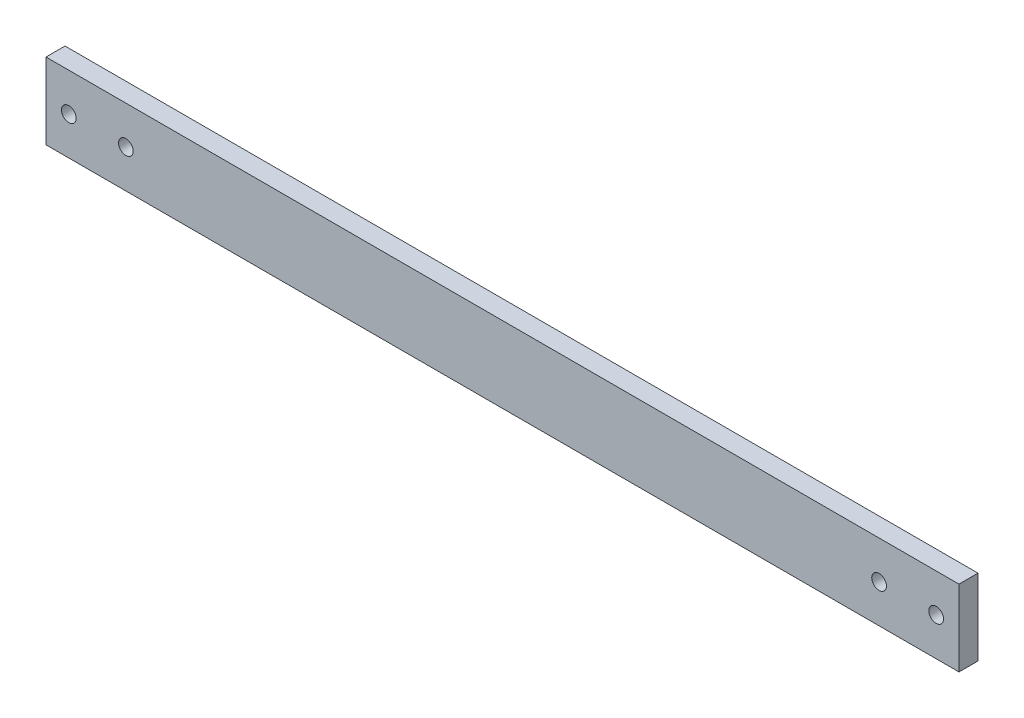
from build123d import *

# Parameters (mm, degrees)
SKETCH1_W                        = 304.8
SKETCH1_H                        = 25.4
BOSS_EXTRUDE1_DEPTH              = 3.175
F_10_0_1935_DIAMETER_HOLE1_D     = 4.9149
F_10_0_1935_DIAMETER_HOLE1_DEPTH = 11.938
F_10_0_1935_DIAMETER_HOLE1_TIP   = 1.476584928


with BuildPart() as part:
    # Sketch1 → Boss-Extrude1 (new body, symmetric)
    with BuildSketch(Plane.XY):
        with Locations((152.4, 0)):
            Rectangle(SKETCH1_W, SKETCH1_H)
    extrude(amount=BOSS_EXTRUDE1_DEPTH, both=True)

    # #10 (0.1935) Diameter Hole1
    with Locations(Plane.XY.offset(3.175)):
        with Locations((7.62, 0), (26.67, 0), (278.13, 0), (297.18, 0)):
            Hole(F_10_0_1935_DIAMETER_HOLE1_D / 2, depth=F_10_0_1935_DIAMETER_HOLE1_DEPTH)
            with Locations((0, 0, -(F_10_0_1935_DIAMETER_HOLE1_DEPTH + F_10_0_1935_DIAMETER_HOLE1_TIP / 2))):  # 118° drill point
                Cone(0, F_10_0_1935_DIAMETER_HOLE1_D / 2, F_10_0_1935_DIAMETER_HOLE1_TIP, mode=Mode.SUBTRACT)


solid = part.part
